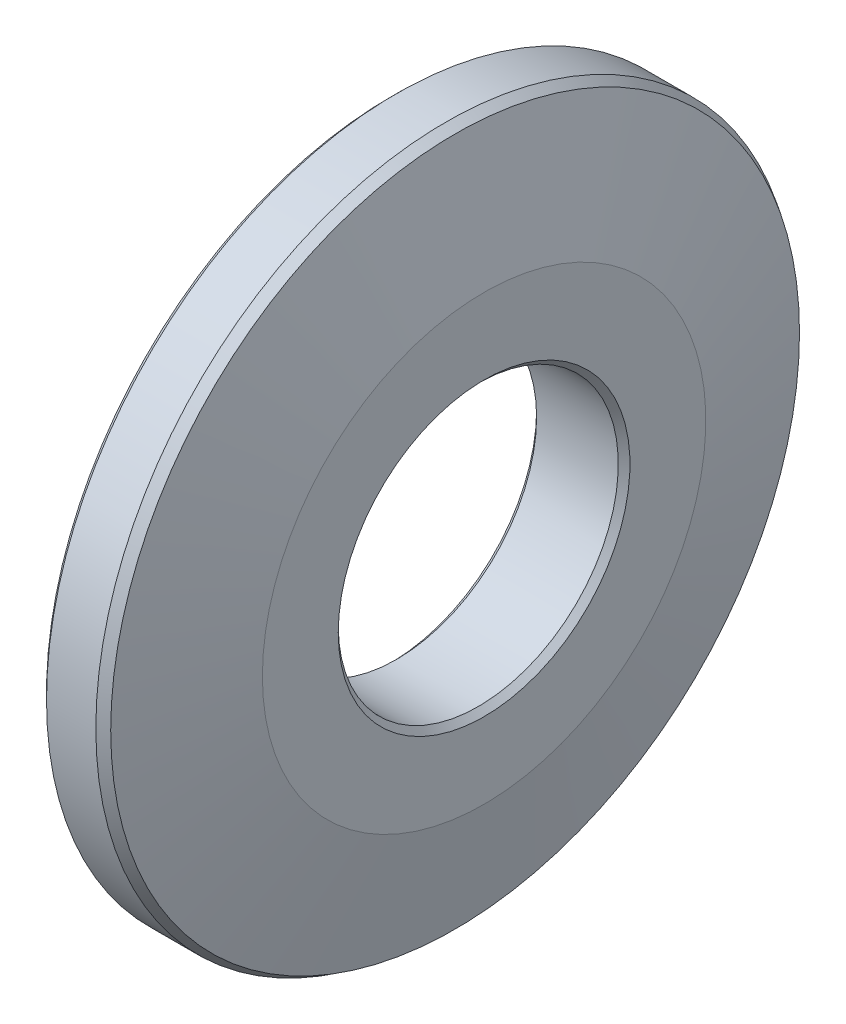
from build123d import *

# Parameters (mm, degrees)
CHAMFER1_SIZE         = 0.25
CHAMFER1_EDGE_2_SIZE  = 0.25
CHAMFER1_EDGE_3_SIZE2 = 0.336401694
CHAMFER1_EDGE_3_SIZE  = 0.25
CHAMFER1_EDGE_4_SIZE  = 0.25


with BuildPart() as part:
    # Sketch1 → Revolve1 (revolve)
    with BuildSketch(Plane(origin=(0, 0, 0), x_dir=(1, 0, 0), z_dir=(0, 1, 0))):
        Polygon((2.7, 15), (4, 9.5), (4, 6), (0, 6), (0, 15), align=None)
    revolve(axis=Axis((0, 0, 0), (1, 0, 0)))

    # Chamfer1
    chamfer1_edges = [part.edges().sort_by_distance(p)[0] for p in [
        (0, 0, 6),
    ]]
    chamfer(chamfer1_edges, length=CHAMFER1_SIZE)

    # Chamfer1 edge 2
    chamfer1_edge_2_edges = [part.edges().sort_by_distance(p)[0] for p in [
        (4, 0, 6),
    ]]
    chamfer(chamfer1_edge_2_edges, length=CHAMFER1_EDGE_2_SIZE)

    # Chamfer1 edge 3
    chamfer1_edge_3_edges = [part.edges().sort_by_distance(p)[0] for p in [
        (2.7, 0, 15),
    ]]
    chamfer(chamfer1_edge_3_edges, length=CHAMFER1_EDGE_3_SIZE, length2=CHAMFER1_EDGE_3_SIZE2)

    # Chamfer1 edge 4
    chamfer1_edge_4_edges = [part.edges().sort_by_distance(p)[0] for p in [
        (0, 0, 15),
    ]]
    chamfer(chamfer1_edge_4_edges, length=CHAMFER1_EDGE_4_SIZE)


solid = part.part
